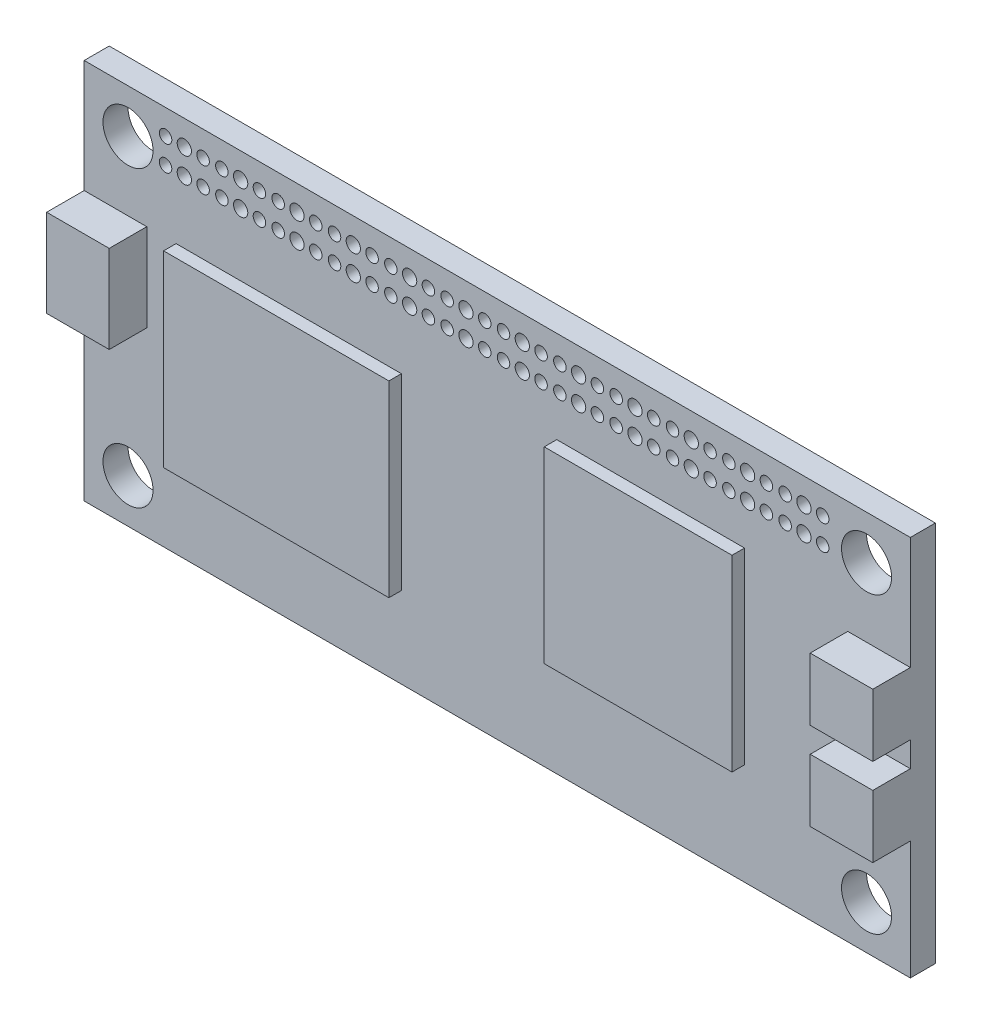
from build123d import *

# Parameters (mm, degrees)
SKETCH1_R           = 2
SKETCH1_W           = 18
SKETCH1_H           = 15
SKETCH1_R_2         = 0.5
SKETCH1_R_3         = 0.5706303
SKETCH1_W_2         = 15
BOSS_EXTRUDE1_DEPTH = 2
SKETCH1_3_W         = 5
SKETCH1_3_H         = 7
SKETCH1_3_H_2       = 5
BOSS_EXTRUDE2_DEPTH = 5
SKETCH1_4_W         = 15
SKETCH1_4_H         = 15
SKETCH1_4_W_2       = 18
BOSS_EXTRUDE3_DEPTH = 3


with BuildPart() as part:
    # Sketch1 → Boss-Extrude1 (new body)
    with BuildSketch(Plane.XY):
        Polygon((3.5, 7.35633001), (-62.5, 7.35633001), (-62.5, -1.64366999), (-57.5, -1.64366999), (-57.5, -8.64366999), (-62.5, -8.64366999), (-62.5, -23.12366999), (3.5, -23.12366999), (3.5, -13.64366999), (-1.5, -13.64366999), (-1.5, -8.64366999), (3.5, -8.64366999), (3.5, -6.64366999), (-1.5, -6.64366999), (-1.5, -1.64366999), (3.5, -1.64366999), align=None)
        with Locations((-59, -19.62366999)):
            Circle(SKETCH1_R, mode=Mode.SUBTRACT)
        with Locations((-46.157324482, -9.14366999)):
            Rectangle(SKETCH1_W, SKETCH1_H, mode=Mode.SUBTRACT)
        with Locations((0, -19.62366999)):
            Circle(SKETCH1_R, mode=Mode.SUBTRACT)
        with Locations((-56, 3.35633001)):
            Circle(SKETCH1_R_2, mode=Mode.SUBTRACT)
        with Locations((-54.5, 3.35633001)):
            Circle(SKETCH1_R_3, mode=Mode.SUBTRACT)
        with Locations((-53, 3.35633001)):
            Circle(SKETCH1_R_2, mode=Mode.SUBTRACT)
        with Locations((-51.5, 3.35633001)):
            Circle(SKETCH1_R_2, mode=Mode.SUBTRACT)
        with Locations((-50, 3.35633001)):
            Circle(SKETCH1_R_3, mode=Mode.SUBTRACT)
        with Locations((-48.5, 3.35633001)):
            Circle(SKETCH1_R_2, mode=Mode.SUBTRACT)
        with Locations((-47, 3.35633001)):
            Circle(SKETCH1_R_2, mode=Mode.SUBTRACT)
        with Locations((-59, 3.85633001)):
            Circle(SKETCH1_R, mode=Mode.SUBTRACT)
        with Locations((-56, 5.35633001)):
            Circle(SKETCH1_R_2, mode=Mode.SUBTRACT)
        with Locations((-54.5, 5.35633001)):
            Circle(SKETCH1_R_3, mode=Mode.SUBTRACT)
        with Locations((-53, 5.35633001)):
            Circle(SKETCH1_R_2, mode=Mode.SUBTRACT)
        with Locations((-51.5, 5.35633001)):
            Circle(SKETCH1_R_2, mode=Mode.SUBTRACT)
        with Locations((-50, 5.35633001)):
            Circle(SKETCH1_R_3, mode=Mode.SUBTRACT)
        with Locations((-48.5, 5.35633001)):
            Circle(SKETCH1_R_2, mode=Mode.SUBTRACT)
        with Locations((-47, 5.35633001)):
            Circle(SKETCH1_R_2, mode=Mode.SUBTRACT)
        with Locations((-45.5, 3.35633001)):
            Circle(SKETCH1_R_3, mode=Mode.SUBTRACT)
        with Locations((-44, 3.35633001)):
            Circle(SKETCH1_R_2, mode=Mode.SUBTRACT)
        with Locations((-42.5, 3.35633001)):
            Circle(SKETCH1_R_2, mode=Mode.SUBTRACT)
        with Locations((-41, 3.35633001)):
            Circle(SKETCH1_R_3, mode=Mode.SUBTRACT)
        with Locations((-39.5, 3.35633001)):
            Circle(SKETCH1_R_2, mode=Mode.SUBTRACT)
        with Locations((-38, 3.35633001)):
            Circle(SKETCH1_R_2, mode=Mode.SUBTRACT)
        with Locations((-36.5, 3.35633001)):
            Circle(SKETCH1_R_3, mode=Mode.SUBTRACT)
        with Locations((-35, 3.35633001)):
            Circle(SKETCH1_R_2, mode=Mode.SUBTRACT)
        with Locations((-33.5, 3.35633001)):
            Circle(SKETCH1_R_2, mode=Mode.SUBTRACT)
        with Locations((-32, 3.35633001)):
            Circle(SKETCH1_R_3, mode=Mode.SUBTRACT)
        with Locations((-30.5, 3.35633001)):
            Circle(SKETCH1_R_2, mode=Mode.SUBTRACT)
        with Locations((-45.5, 5.35633001)):
            Circle(SKETCH1_R_3, mode=Mode.SUBTRACT)
        with Locations((-44, 5.35633001)):
            Circle(SKETCH1_R_2, mode=Mode.SUBTRACT)
        with Locations((-42.5, 5.35633001)):
            Circle(SKETCH1_R_2, mode=Mode.SUBTRACT)
        with Locations((-41, 5.35633001)):
            Circle(SKETCH1_R_3, mode=Mode.SUBTRACT)
        with Locations((-39.5, 5.35633001)):
            Circle(SKETCH1_R_2, mode=Mode.SUBTRACT)
        with Locations((-38, 5.35633001)):
            Circle(SKETCH1_R_2, mode=Mode.SUBTRACT)
        with Locations((-36.5, 5.35633001)):
            Circle(SKETCH1_R_3, mode=Mode.SUBTRACT)
        with Locations((-35, 5.35633001)):
            Circle(SKETCH1_R_2, mode=Mode.SUBTRACT)
        with Locations((-33.5, 5.35633001)):
            Circle(SKETCH1_R_2, mode=Mode.SUBTRACT)
        with Locations((-32, 5.35633001)):
            Circle(SKETCH1_R_3, mode=Mode.SUBTRACT)
        with Locations((-30.5, 5.35633001)):
            Circle(SKETCH1_R_2, mode=Mode.SUBTRACT)
        with Locations((-17.247739958, -7.5)):
            Rectangle(SKETCH1_W_2, SKETCH1_H, mode=Mode.SUBTRACT)
        with Locations((-29, 3.35633001)):
            Circle(SKETCH1_R_2, mode=Mode.SUBTRACT)
        with Locations((-27.5, 3.35633001)):
            Circle(SKETCH1_R_3, mode=Mode.SUBTRACT)
        with Locations((-26, 3.35633001)):
            Circle(SKETCH1_R_2, mode=Mode.SUBTRACT)
        with Locations((-24.5, 3.35633001)):
            Circle(SKETCH1_R_2, mode=Mode.SUBTRACT)
        with Locations((-23, 3.35633001)):
            Circle(SKETCH1_R_3, mode=Mode.SUBTRACT)
        with Locations((-21.5, 3.35633001)):
            Circle(SKETCH1_R_2, mode=Mode.SUBTRACT)
        with Locations((-20, 3.35633001)):
            Circle(SKETCH1_R_2, mode=Mode.SUBTRACT)
        with Locations((-18.5, 3.35633001)):
            Circle(SKETCH1_R_3, mode=Mode.SUBTRACT)
        with Locations((-17, 3.35633001)):
            Circle(SKETCH1_R_2, mode=Mode.SUBTRACT)
        with Locations((-15.5, 3.35633001)):
            Circle(SKETCH1_R_2, mode=Mode.SUBTRACT)
        with Locations((-14, 3.35633001)):
            Circle(SKETCH1_R_3, mode=Mode.SUBTRACT)
        with Locations((-29, 5.35633001)):
            Circle(SKETCH1_R_2, mode=Mode.SUBTRACT)
        with Locations((-27.5, 5.35633001)):
            Circle(SKETCH1_R_3, mode=Mode.SUBTRACT)
        with Locations((-26, 5.35633001)):
            Circle(SKETCH1_R_2, mode=Mode.SUBTRACT)
        with Locations((-24.5, 5.35633001)):
            Circle(SKETCH1_R_2, mode=Mode.SUBTRACT)
        with Locations((-23, 5.35633001)):
            Circle(SKETCH1_R_3, mode=Mode.SUBTRACT)
        with Locations((-21.5, 5.35633001)):
            Circle(SKETCH1_R_2, mode=Mode.SUBTRACT)
        with Locations((-20, 5.35633001)):
            Circle(SKETCH1_R_2, mode=Mode.SUBTRACT)
        with Locations((-18.5, 5.35633001)):
            Circle(SKETCH1_R_3, mode=Mode.SUBTRACT)
        with Locations((-17, 5.35633001)):
            Circle(SKETCH1_R_2, mode=Mode.SUBTRACT)
        with Locations((-15.5, 5.35633001)):
            Circle(SKETCH1_R_2, mode=Mode.SUBTRACT)
        with Locations((-14, 5.35633001)):
            Circle(SKETCH1_R_3, mode=Mode.SUBTRACT)
        with Locations((-12.5, 3.35633001)):
            Circle(SKETCH1_R_2, mode=Mode.SUBTRACT)
        with Locations((-11, 3.35633001)):
            Circle(SKETCH1_R_2, mode=Mode.SUBTRACT)
        with Locations((-9.5, 3.35633001)):
            Circle(SKETCH1_R_3, mode=Mode.SUBTRACT)
        with Locations((-8, 3.35633001)):
            Circle(SKETCH1_R_2, mode=Mode.SUBTRACT)
        with Locations((-6.5, 3.35633001)):
            Circle(SKETCH1_R_2, mode=Mode.SUBTRACT)
        with Locations((-5, 3.35633001)):
            Circle(SKETCH1_R_3, mode=Mode.SUBTRACT)
        with Locations((-3.5, 3.35633001)):
            Circle(SKETCH1_R_2, mode=Mode.SUBTRACT)
        with Locations((-12.5, 5.35633001)):
            Circle(SKETCH1_R_2, mode=Mode.SUBTRACT)
        with Locations((-11, 5.35633001)):
            Circle(SKETCH1_R_2, mode=Mode.SUBTRACT)
        with Locations((-9.5, 5.35633001)):
            Circle(SKETCH1_R_3, mode=Mode.SUBTRACT)
        with Locations((-8, 5.35633001)):
            Circle(SKETCH1_R_2, mode=Mode.SUBTRACT)
        with Locations((-6.5, 5.35633001)):
            Circle(SKETCH1_R_2, mode=Mode.SUBTRACT)
        with Locations((-5, 5.35633001)):
            Circle(SKETCH1_R_3, mode=Mode.SUBTRACT)
        with Locations((-3.5, 5.35633001)):
            Circle(SKETCH1_R_2, mode=Mode.SUBTRACT)
        with Locations((0, 3.85633001)):
            Circle(SKETCH1_R, mode=Mode.SUBTRACT)
    extrude(amount=BOSS_EXTRUDE1_DEPTH)

    # Sketch1_3 → Boss-Extrude2 (add)
    with BuildSketch(Plane.XY):
        with Locations((-60, -5.14366999)):
            Rectangle(SKETCH1_3_W, SKETCH1_3_H)
        with Locations((1, -4.14366999)):
            Rectangle(SKETCH1_3_W, SKETCH1_3_H_2)
        with Locations((1, -11.14366999)):
            Rectangle(SKETCH1_3_W, SKETCH1_3_H_2)
    extrude(amount=BOSS_EXTRUDE2_DEPTH)

    # Sketch1_4 → Boss-Extrude3 (add)
    with BuildSketch(Plane.XY):
        with Locations((-17.247739958, -7.5)):
            Rectangle(SKETCH1_4_W, SKETCH1_4_H)
        with Locations((-46.157324482, -9.14366999)):
            Rectangle(SKETCH1_4_W_2, SKETCH1_4_H)
    extrude(amount=BOSS_EXTRUDE3_DEPTH)


solid = part.part
